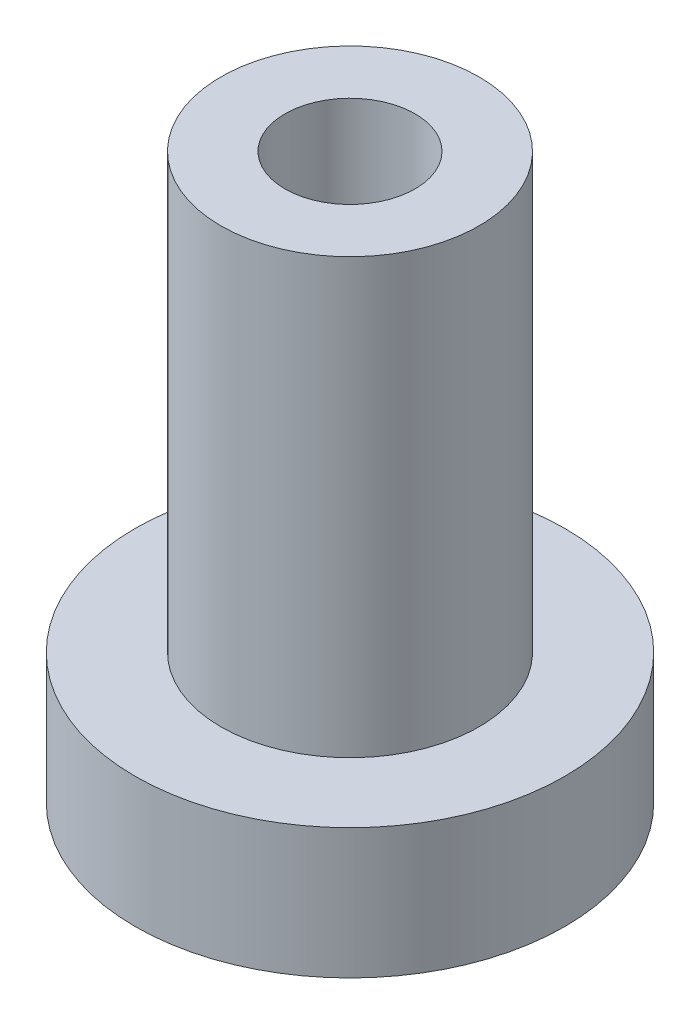
from build123d import *

# Parameters (mm, degrees)
SKETCH_1_R          = 9.9
EXTRUDE_1_DEPTH     = 6
SKETCH_2_R          = 5.95
EXTRUDE_2_DEPTH     = 20
SKETCH_3_R          = 3
CUT_EXTRUDE_1_DEPTH = 35


with BuildPart() as part:
    # Эскиз1 → Бобышка-Вытянуть1 (new body)
    with BuildSketch(Plane(origin=(0, 0, 0), x_dir=(1, 0, 0), z_dir=(0, 1, 0))):
        Circle(SKETCH_1_R)
    extrude(amount=EXTRUDE_1_DEPTH)

    # Эскиз2 → Бобышка-Вытянуть2 (add)
    with BuildSketch(Plane(origin=(0, 6, 0), x_dir=(1, 0, 0), z_dir=(0, 1, 0))):
        Circle(SKETCH_2_R)
    extrude(amount=EXTRUDE_2_DEPTH)

    # Эскиз3 → Вырез-Вытянуть1 (cut)
    with BuildSketch(Plane(origin=(0, 26, 0), x_dir=(1, 0, 0), z_dir=(0, 1, 0))):
        Circle(SKETCH_3_R)
    extrude(amount=-CUT_EXTRUDE_1_DEPTH, mode=Mode.SUBTRACT)


solid = part.part
